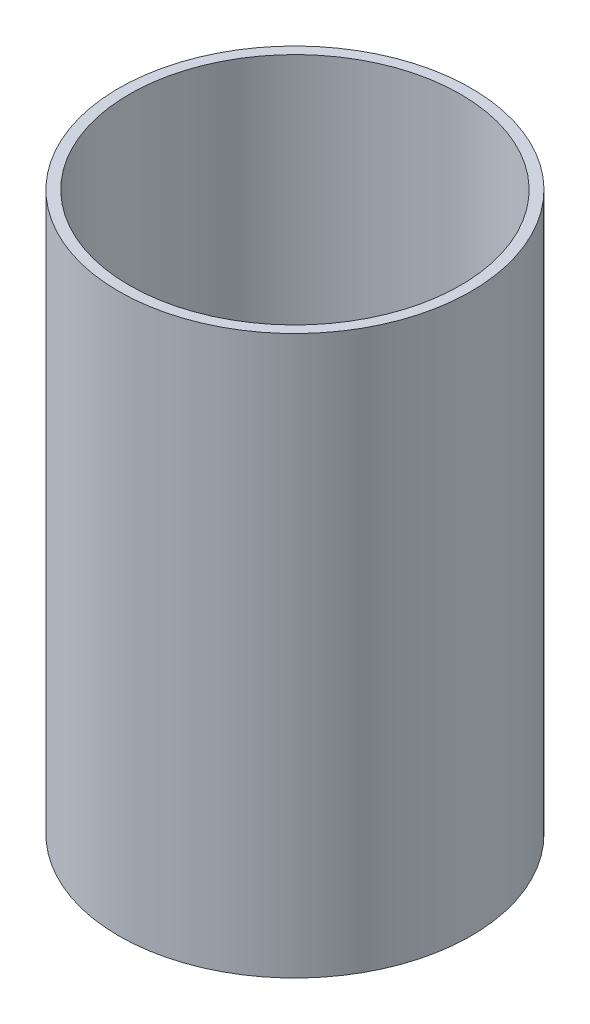
from build123d import *

# Parameters (mm, degrees)
SKETCH1_R           = 25.175
SKETCH1_R_2         = 23.675
BOSS_EXTRUDE1_DEPTH = 79.8


with BuildPart() as part:
    # Sketch1 → Boss-Extrude1 (new body)
    with BuildSketch(Plane(origin=(0, 0, 0), x_dir=(1, 0, 0), z_dir=(0, 1, 0))):
        Circle(SKETCH1_R)
        Circle(SKETCH1_R_2, mode=Mode.SUBTRACT)
    extrude(amount=BOSS_EXTRUDE1_DEPTH)


solid = part.part
